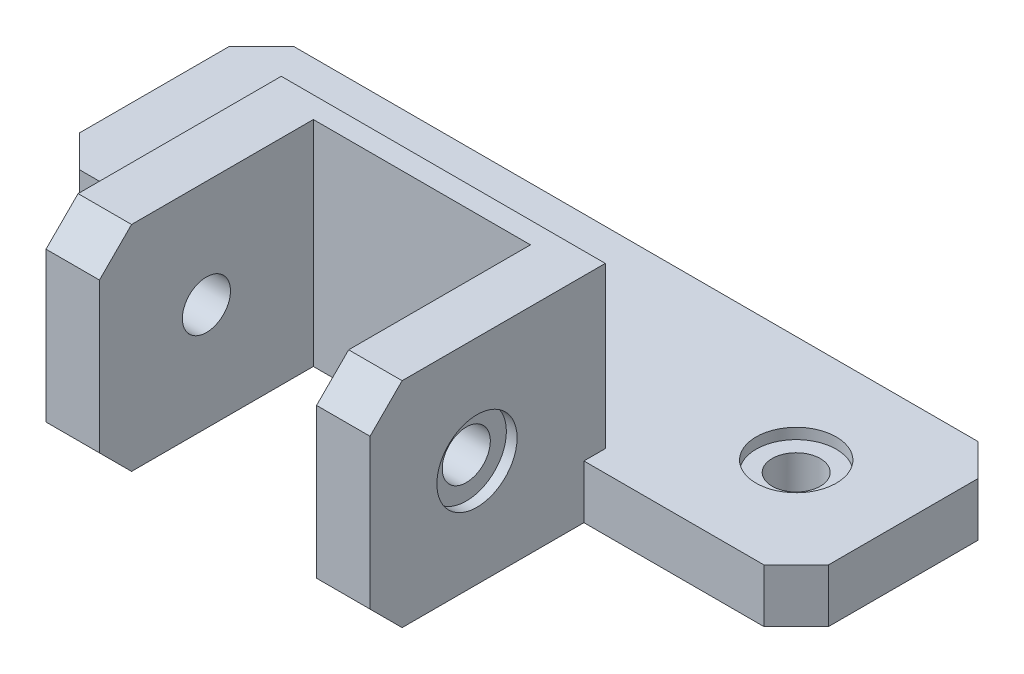
from build123d import *

# Parameters (mm, degrees)
SKETCH3_W                = 70
SKETCH3_H                = 20
BOSS_EXTRUDE2_DEPTH      = 5
BOSS_EXTRUDE3_DEPTH      = 15
BOSS_EXTRUDE3_DEPTH_BACK = 5
CUT_EXTRUDE1_REACH       = 7
SKETCH5_R                = 2.25
SKETCH6_R                = 3.75
CUT_EXTRUDE2_DEPTH       = 16
CUT_EXTRUDE2_DEPTH_BACK  = 1
SKETCH7_R                = 2.25
CUT_EXTRUDE3_DEPTH       = 20.85
CUT_EXTRUDE3_DEPTH_BACK  = 51.15
SKETCH11_R               = 3.75
CUT_EXTRUDE4_DEPTH       = 1
SKETCH12_R               = 3.75
CUT_EXTRUDE5_DEPTH       = 1
CHAMFER1_SIZE            = 3


with BuildPart() as part:
    # Sketch3 → Boss-Extrude2 (new body)
    with BuildSketch(Plane(origin=(0, 0, 0), x_dir=(1, 0, 0), z_dir=(0, 1, 0))):
        Rectangle(SKETCH3_W, SKETCH3_H)
    extrude(amount=BOSS_EXTRUDE2_DEPTH)

    # Sketch4 → Boss-Extrude3 (add, two sides)
    with BuildSketch(Plane(origin=(0, 5, 0), x_dir=(1, 0, 0), z_dir=(0, 1, 0))) as boss_extrude3_sk:
        Polygon((-15.15, -5), (15.15, -5), (15.15, -30), (10.15, -30), (10.15, -10), (-10.15, -10), (-10.15, -30), (-15.15, -30), align=None)
    extrude(amount=BOSS_EXTRUDE3_DEPTH)
    extrude(boss_extrude3_sk.sketch, amount=-BOSS_EXTRUDE3_DEPTH_BACK)

    # Sketch5 → Cut-Extrude1 (cut, up to next)
    with BuildSketch(Plane(origin=(0, 5, 0), x_dir=(1, 0, 0), z_dir=(0, 1, 0)), mode=Mode.PRIVATE) as cut_extrude1_sk1:
        Circle(SKETCH5_R)
    cut_extrude1_tool1 = extrude(cut_extrude1_sk1.sketch, amount=-CUT_EXTRUDE1_REACH, mode=Mode.PRIVATE) & part.part
    add(cut_extrude1_tool1.solids().sort_by_distance((0, 5, 0))[0], mode=Mode.SUBTRACT)
    # Sketch5 → Cut-Extrude1 (cut, up to next)
    with BuildSketch(Plane(origin=(0, 5, 0), x_dir=(1, 0, 0), z_dir=(0, 1, 0)), mode=Mode.PRIVATE) as cut_extrude1_sk2:
        with Locations((25, 0)):
            Circle(SKETCH5_R)
    cut_extrude1_tool2 = extrude(cut_extrude1_sk2.sketch, amount=-CUT_EXTRUDE1_REACH, mode=Mode.PRIVATE) & part.part
    add(cut_extrude1_tool2.solids().sort_by_distance((25, 5, 0))[0], mode=Mode.SUBTRACT)
    # Sketch5 → Cut-Extrude1 (cut, up to next)
    with BuildSketch(Plane(origin=(0, 5, 0), x_dir=(1, 0, 0), z_dir=(0, 1, 0)), mode=Mode.PRIVATE) as cut_extrude1_sk3:
        with Locations((-25, 0)):
            Circle(SKETCH5_R)
    cut_extrude1_tool3 = extrude(cut_extrude1_sk3.sketch, amount=-CUT_EXTRUDE1_REACH, mode=Mode.PRIVATE) & part.part
    add(cut_extrude1_tool3.solids().sort_by_distance((-25, 5, 0))[0], mode=Mode.SUBTRACT)

    # Sketch6 → Cut-Extrude2 (cut, two sides)
    with BuildSketch(Plane(origin=(0, 5, 0), x_dir=(1, 0, 0), z_dir=(0, 1, 0))) as cut_extrude2_sk:
        with Locations((-25, 0)):
            Circle(SKETCH6_R)
        Circle(SKETCH6_R)
        with Locations((25, 0)):
            Circle(SKETCH6_R)
    extrude(amount=CUT_EXTRUDE2_DEPTH, mode=Mode.SUBTRACT)
    extrude(cut_extrude2_sk.sketch, amount=-CUT_EXTRUDE2_DEPTH_BACK, mode=Mode.SUBTRACT)

    # Sketch7 → Cut-Extrude3 (cut, two sides)
    with BuildSketch(Plane.ZY.offset(15.15)) as cut_extrude3_sk:
        with Locations((20, 10)):
            Circle(SKETCH7_R)
    extrude(amount=CUT_EXTRUDE3_DEPTH, mode=Mode.SUBTRACT)
    extrude(cut_extrude3_sk.sketch, amount=-CUT_EXTRUDE3_DEPTH_BACK, mode=Mode.SUBTRACT)

    # Sketch11 → Cut-Extrude4 (cut)
    with BuildSketch(Plane.ZY.offset(15.15)):
        with Locations((20, 10)):
            Circle(SKETCH11_R)
    extrude(amount=-CUT_EXTRUDE4_DEPTH, mode=Mode.SUBTRACT)

    # Sketch12 → Cut-Extrude5 (cut)
    with BuildSketch(Plane(origin=(15.15, 0, 0), x_dir=(0, 0, -1), z_dir=(1, 0, 0))):
        with Locations((-20, 10)):
            Circle(SKETCH12_R)
    extrude(amount=-CUT_EXTRUDE5_DEPTH, mode=Mode.SUBTRACT)

    # Chamfer1
    chamfer1_edges = [part.edges().sort_by_distance(p)[0] for p in [
        (15.15, 12.5, 5),
        (-15.15, 12.5, 5),
        (-12.65, 0, 30),
        (12.65, 0, 30),
        (0, 20, 5),
        (-12.65, 20, 30),
        (12.65, 20, 30),
        (35, 2.5, 10),
        (-35, 2.5, 10),
        (-35, 2.5, -10),
        (35, 2.5, -10),
    ]]
    chamfer(chamfer1_edges, length=CHAMFER1_SIZE)


solid = part.part
